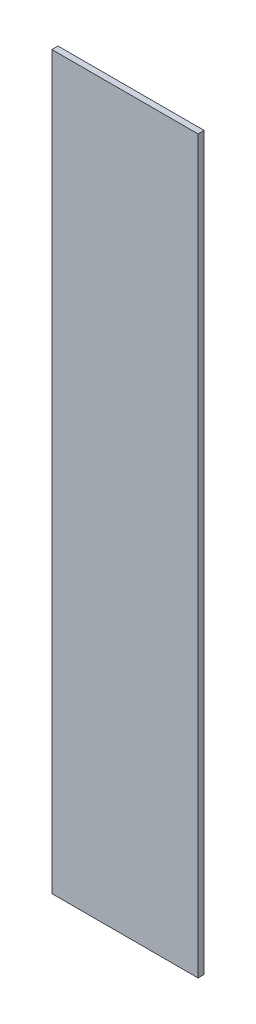
from build123d import *

# Parameters (mm, degrees)
SKETCH1_W           = 120
SKETCH1_H           = 600
BOSS_EXTRUDE1_DEPTH = 5


with BuildPart() as part:
    # Sketch1 → Boss-Extrude1 (new body)
    with BuildSketch(Plane.XY):
        Rectangle(SKETCH1_W, SKETCH1_H)
    extrude(amount=BOSS_EXTRUDE1_DEPTH)


solid = part.part
